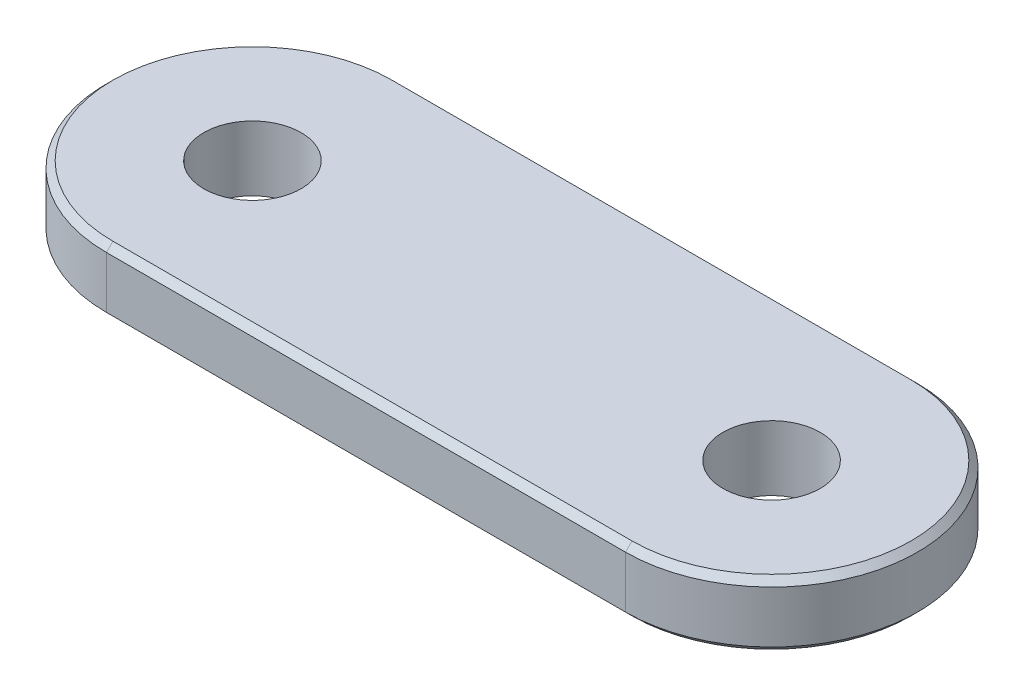
from build123d import *

# Parameters (mm, degrees)
BOSS_EXTRUDE1_DEPTH = 20
SKETCH2_R           = 15
CUT_EXTRUDE1_DEPTH  = 21
CHAMFER1_SIZE       = 2


with BuildPart() as part:
    # Sketch1 → Boss-Extrude1 (new body)
    with BuildSketch(Plane(origin=(0, 0, 0), x_dir=(1, 0, 0), z_dir=(0, 1, 0))):
        with BuildLine():
            Line((-80, 45), (80, 45))
            ThreePointArc((80, 45), (125, 0), (80, -45))
            Line((80, -45), (-80, -45))
            ThreePointArc((-80, -45), (-125, 0), (-80, 45))
        make_face()
    extrude(amount=BOSS_EXTRUDE1_DEPTH)

    # Sketch2 → Cut-Extrude1 (cut, through all)
    with BuildSketch(Plane(origin=(0, 20, 0), x_dir=(1, 0, 0), z_dir=(0, 1, 0))):
        with Locations((-80, 0)):
            Circle(SKETCH2_R)
        with Locations((80, 0)):
            Circle(SKETCH2_R)
    extrude(amount=-CUT_EXTRUDE1_DEPTH, mode=Mode.SUBTRACT)

    # Chamfer1
    chamfer1_edges = [part.edges().sort_by_distance(p)[0] for p in [
        (125, 20, 0),
        (0, 20, -45),
        (-125, 20, 0),
        (0, 0, -45),
        (125, 0, 0),
        (0, 0, 45),
        (-125, 0, 0),
        (0, 20, 45),
    ]]
    chamfer(chamfer1_edges, length=CHAMFER1_SIZE)


solid = part.part
